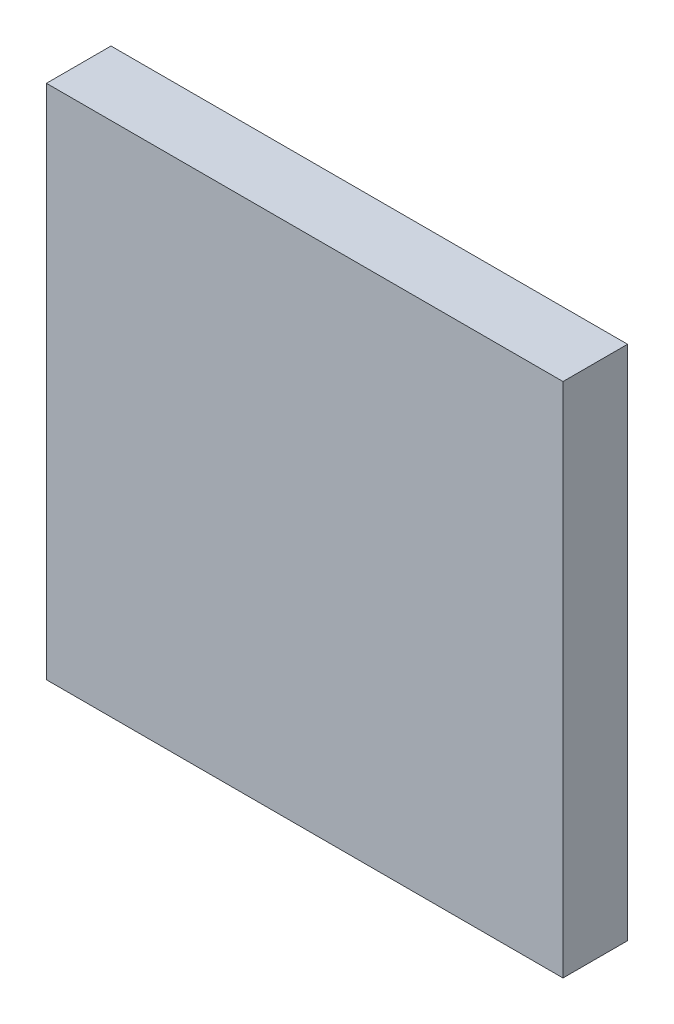
from build123d import *

# Parameters (mm, degrees)
SKETCH1_W           = 40
SKETCH1_H           = 40
BOSS_EXTRUDE1_DEPTH = 5


with BuildPart() as part:
    # Sketch1 → Boss-Extrude1 (new body)
    with BuildSketch(Plane.XY):
        Rectangle(SKETCH1_W, SKETCH1_H)
    extrude(amount=BOSS_EXTRUDE1_DEPTH)


solid = part.part
